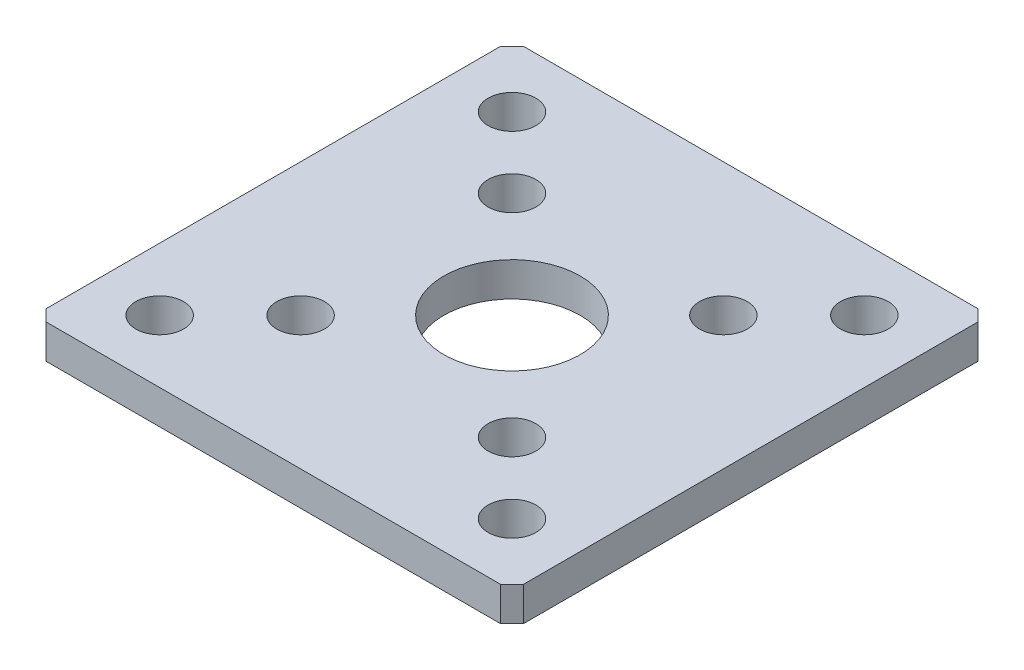
from build123d import *

# Parameters (mm, degrees)
SKETCH_1_W               = 42
SKETCH_1_H               = 42
EXTRUDE_1_DEPTH          = 3
SKETCH_2_R               = 6
CUT_EXTRUDE_1_DEPTH      = 4
SKETCH_4_R               = 2.1
CUT_EXTRUDE_2_DEPTH      = 4
SKETCH_5_R               = 2.1
CUT_EXTRUDE_3_DEPTH      = 4
PATTERN_CIRCULAR_1_COUNT = 4
CHAMFER_1_SIZE           = 1


with BuildPart() as part:
    # 草圖1 → 填料-伸長1 (new body)
    with BuildSketch(Plane(origin=(0, 0, 0), x_dir=(1, 0, 0), z_dir=(0, 1, 0))):
        Rectangle(SKETCH_1_W, SKETCH_1_H)
    extrude(amount=EXTRUDE_1_DEPTH)

    # 草圖2 → 除料-伸長1 (cut, through all)
    with BuildSketch(Plane.XZ):
        Circle(SKETCH_2_R)
    extrude(amount=-CUT_EXTRUDE_1_DEPTH, mode=Mode.SUBTRACT)

    # 草圖4 → 除料-伸長2 (cut, through all)
    with BuildSketch(Plane(origin=(0, 3, 0), x_dir=(1, 0, 0), z_dir=(0, 1, 0))):
        with Locations((-9.3, 9.3)):
            Circle(SKETCH_4_R)
    cut_extrude_2 = extrude(amount=-CUT_EXTRUDE_2_DEPTH, mode=Mode.SUBTRACT)

    # 草圖5 → 除料-伸長3 (cut, through all)
    with BuildSketch(Plane(origin=(0, 3, 0), x_dir=(1, 0, 0), z_dir=(0, 1, 0))):
        with Locations((-15.5, 15.5)):
            Circle(SKETCH_5_R)
    cut_extrude_3 = extrude(amount=-CUT_EXTRUDE_3_DEPTH, mode=Mode.SUBTRACT)

    # 環狀複製排列1: 除料-伸長2, 除料-伸長3 ×4 about axis
    pattern_circular_1_axis = Axis((0, 0, 0), (0, 1, 0))
    for i in range(1, PATTERN_CIRCULAR_1_COUNT):
        add(cut_extrude_2.rotate(pattern_circular_1_axis, i * 360 / PATTERN_CIRCULAR_1_COUNT), mode=Mode.SUBTRACT)
        add(cut_extrude_3.rotate(pattern_circular_1_axis, i * 360 / PATTERN_CIRCULAR_1_COUNT), mode=Mode.SUBTRACT)

    # 導角1
    chamfer_1_edges = [part.edges().sort_by_distance(p)[0] for p in [
        (21, 1.5, 21),
        (-21, 1.5, 21),
        (-21, 1.5, -21),
        (21, 1.5, -21),
    ]]
    chamfer(chamfer_1_edges, length=CHAMFER_1_SIZE)


solid = part.part
